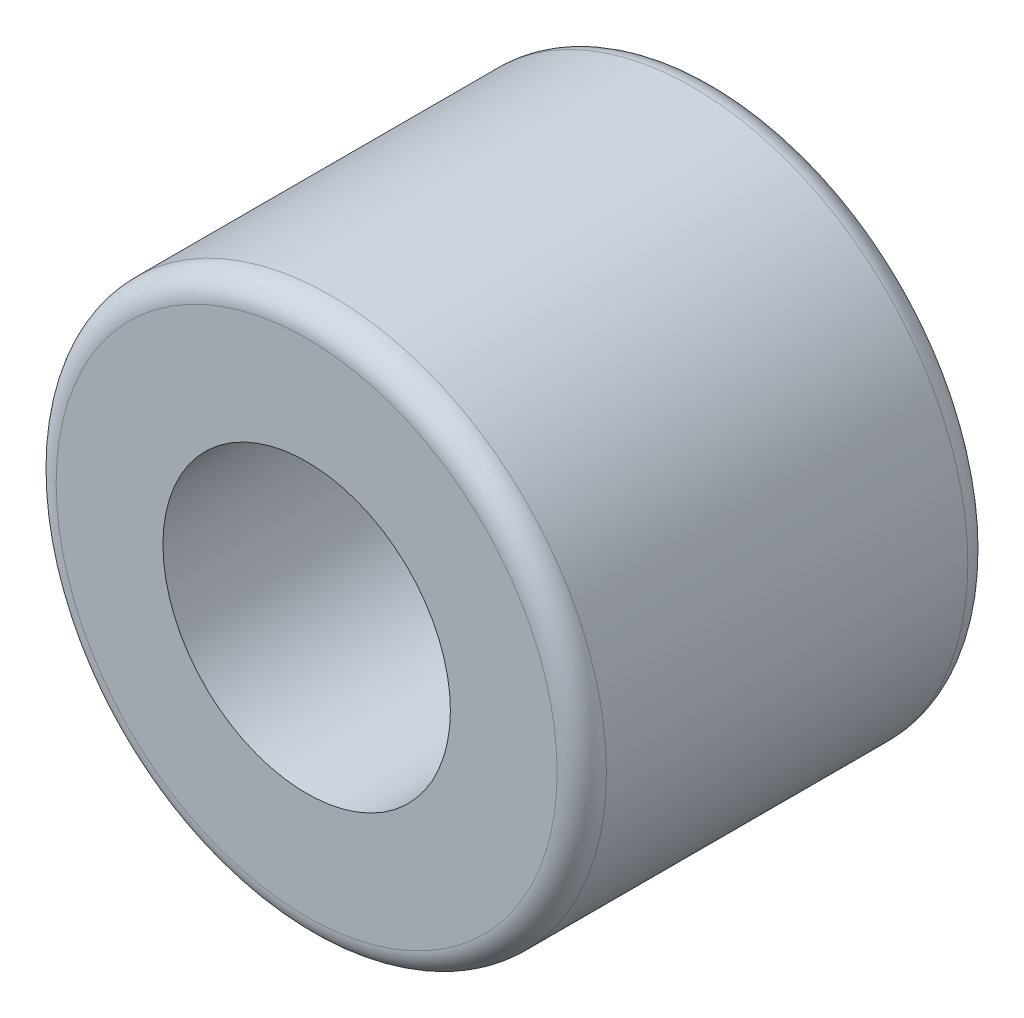
from build123d import *

# Parameters (mm, degrees)
IZIM1_R                     = 8.509
IZIM1_R_2                   = 4.445
Y_KSEKLIK_EKSTR_ZYON1_DEPTH = 12.7
RADYUS1_R                   = 0.762


with BuildPart() as part:
    # Çizim1 → Yükseklik-Ekstrüzyon1 (new body)
    with BuildSketch(Plane.XY):
        Circle(IZIM1_R)
        Circle(IZIM1_R_2, mode=Mode.SUBTRACT)
    extrude(amount=Y_KSEKLIK_EKSTR_ZYON1_DEPTH)

    # Radyus1
    radyus1_edges = [part.edges().sort_by_distance(p)[0] for p in [
        (-8.509, 0, 0),
        (-8.509, 0, 12.7),
    ]]
    fillet(radyus1_edges, radius=RADYUS1_R)


solid = part.part
